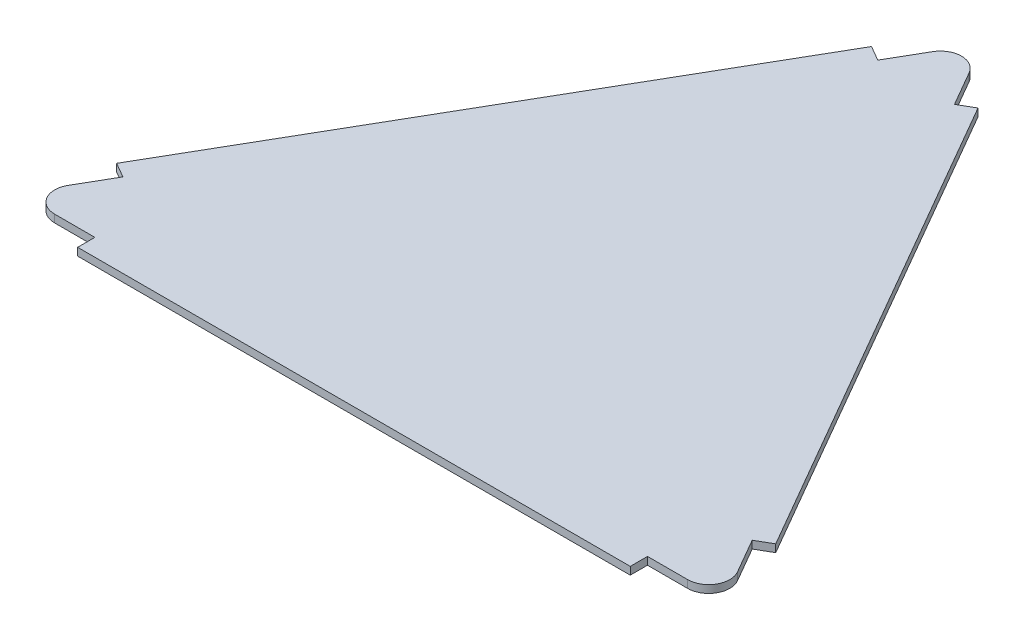
from build123d import *

# Parameters (mm, degrees)
BOSS_EXTRUDE2_DEPTH = 2
CUT_EXTRUDE1_START  = -5
CUT_EXTRUDE1_DEPTH  = 5
CIRPATTERN1_COUNT   = 3


with BuildPart() as part:
    # Sketch2 → Boss-Extrude2 (new body)
    with BuildSketch(Plane(origin=(0, 0, 0), x_dir=(1, 0, 0), z_dir=(0, 1, 0))):
        with BuildLine():
            ThreePointArc((8.660254038, 100.470053838), (0, 105.470053838), (-8.660254038, 100.470053838))
            Line((-8.660254038, 100.470053838), (-91.339745962, -42.735026919))
            ThreePointArc((-91.339745962, -42.735026919), (-91.339745962, -52.735026919), (-82.679491924, -57.735026919))
            Line((-82.679491924, -57.735026919), (82.679491924, -57.735026919))
            ThreePointArc((82.679491924, -57.735026919), (91.339745962, -52.735026919), (91.339745962, -42.735026919))
            Line((91.339745962, -42.735026919), (8.660254038, 100.470053838))
        make_face()
    extrude(amount=BOSS_EXTRUDE2_DEPTH)

    # Sketch6 → Cut-Extrude1 (cut)
    with BuildSketch(Plane(origin=(0, 2, 0), x_dir=(1, 0, 0), z_dir=(0, 1, 0)).offset(CUT_EXTRUDE1_START)):
        with BuildLine():
            Line((-8.660254038, 100.470053838), (-13.660254038, 91.8097998))
            Line((-13.660254038, 91.8097998), (-13.910254038, 91.376787098))
            Line((-13.910254038, 91.376787098), (-10.013139721, 89.126787098))
            Line((-10.013139721, 89.126787098), (-4.763139721, 98.220053838))
            ThreePointArc((-4.763139721, 98.220053838), (-2.75, 100.233193559), (0, 100.970053838))
            Line((0, 100.970053838), (0, 101.470053838))
            Line((0, 101.470053838), (0, 105.470053838))
            ThreePointArc((0, 105.470053838), (-5, 104.130307876), (-8.660254038, 100.470053838))
        make_face()
        with BuildLine():
            Line((-91.339745962, -42.735026919), (-86.339745962, -34.074772881))
            Line((-86.339745962, -34.074772881), (-86.089745962, -33.641760179))
            Line((-86.089745962, -33.641760179), (-82.192631645, -35.891760179))
            Line((-82.192631645, -35.891760179), (-87.442631645, -44.985026919))
            ThreePointArc((-87.442631645, -44.985026919), (-88.173795368, -47.985286122), (-87.172908415, -50.906652408))
            Line((-87.172908415, -50.906652408), (-91.089745962, -53.168039621))
            Line((-91.089745962, -53.168039621), (-91.339745962, -52.735026919))
            ThreePointArc((-91.339745962, -52.735026919), (-92.679491924, -47.735026919), (-91.339745962, -42.735026919))
        make_face()
    cut_extrude1 = extrude(amount=CUT_EXTRUDE1_DEPTH, mode=Mode.SUBTRACT)

    # CirPattern1: Cut-Extrude1 ×3 about axis
    cirpattern1_axis = Axis((0, 0, 0), (0, 1, 0))
    for i in range(1, CIRPATTERN1_COUNT):
        add(cut_extrude1.rotate(cirpattern1_axis, i * 360 / CIRPATTERN1_COUNT), mode=Mode.SUBTRACT)


solid = part.part
